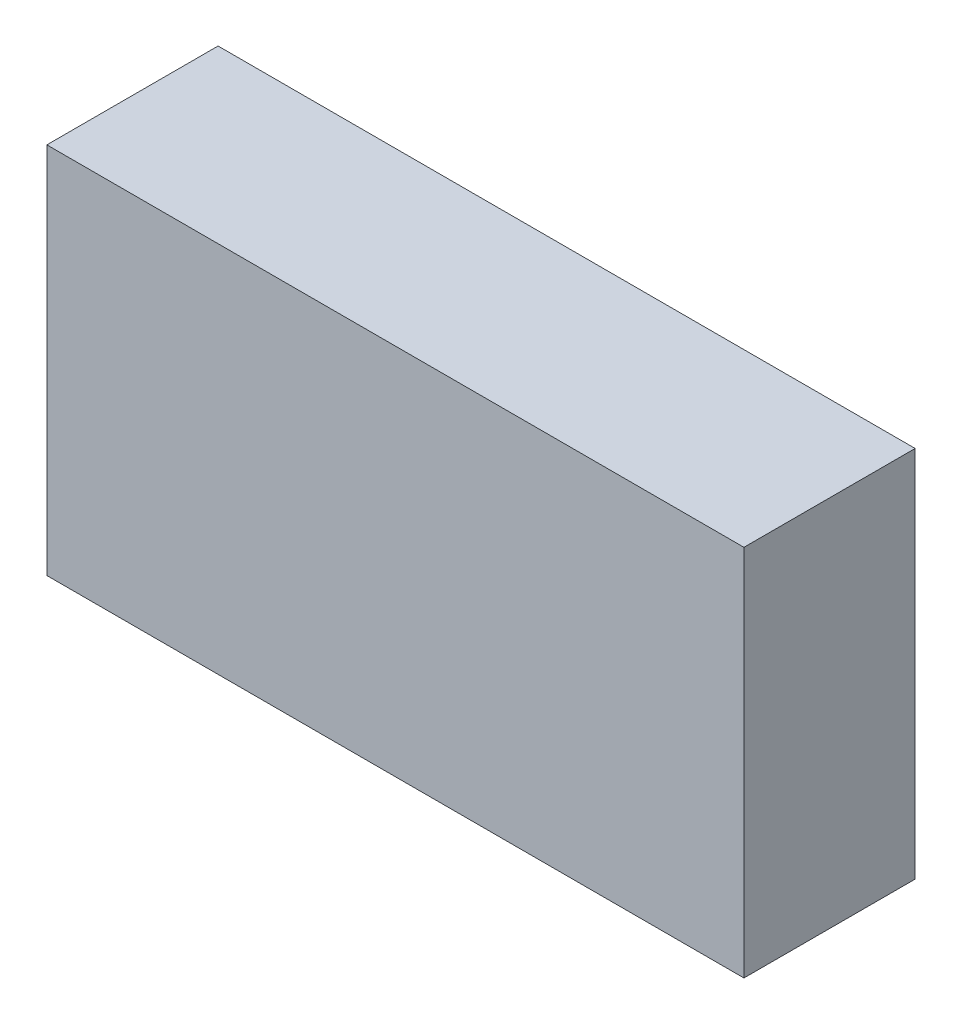
from build123d import *

# Parameters (mm, degrees)
SKETCH1_W           = 57
SKETCH1_H           = 30.5
BOSS_EXTRUDE1_DEPTH = 14


with BuildPart() as part:
    # Sketch1 → Boss-Extrude1 (new body)
    with BuildSketch(Plane.XY):
        Rectangle(SKETCH1_W, SKETCH1_H)
    extrude(amount=BOSS_EXTRUDE1_DEPTH)


solid = part.part
